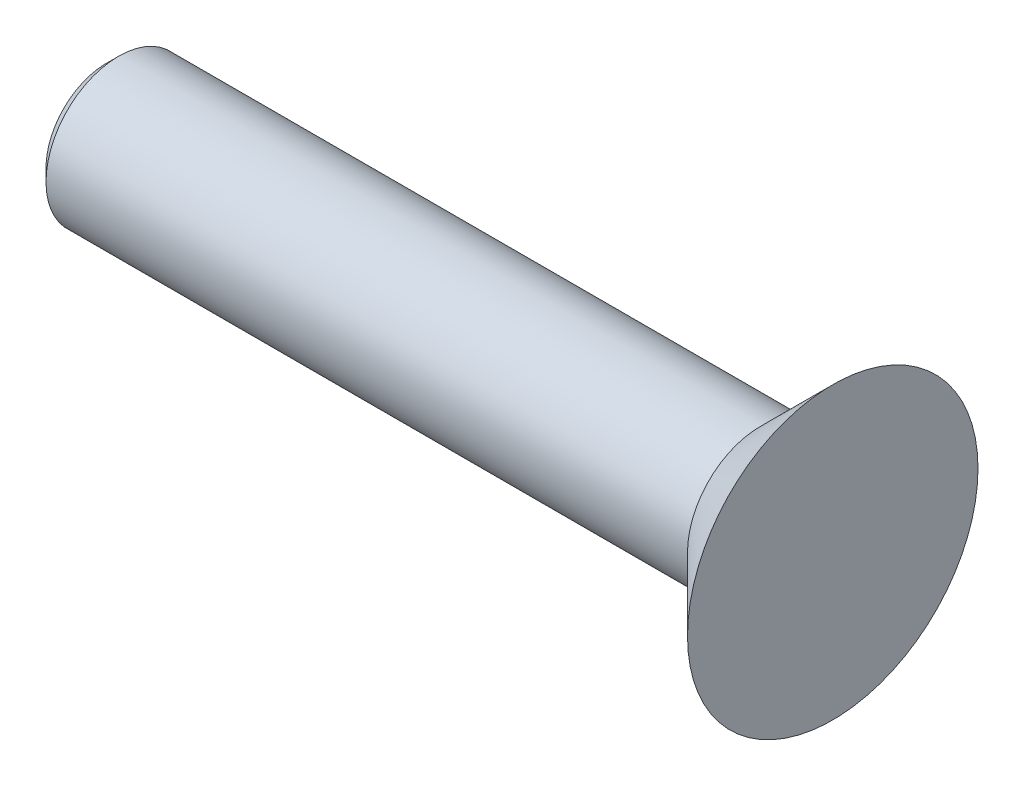
from build123d import *

# Parameters (mm, degrees)
CHANFREIN1_SIZE = 0.25


with BuildPart() as part:
    # Esquisse1 → Révolution1 (revolve)
    with BuildSketch(Plane.XY, mode=Mode.PRIVATE) as r_volution1_sk:
        Polygon((0, 0), (-15, 0), (-15, 1.5), (-1.5, 1.5), (0, 3), align=None)
    revolve(r_volution1_sk.sketch.rotate(Axis((0, 0, 0), (1, 0, 0)), 90), axis=Axis((0, 0, 0), (1, 0, 0)))  # turned: the seam where the file's is

    # Chanfrein1
    chanfrein1_edges = [part.edges().sort_by_distance(p)[0] for p in [
        (-15, 0, -1.5),
    ]]
    chamfer(chanfrein1_edges, length=CHANFREIN1_SIZE)


solid = part.part
